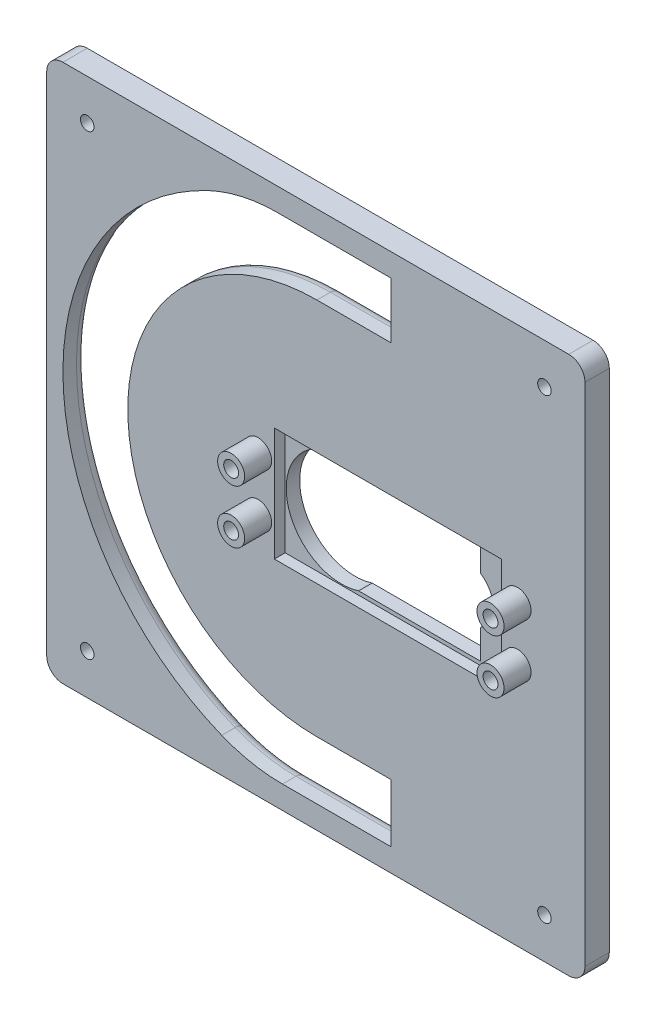
from build123d import *

# Parameters (mm, degrees)
SKETCH1_W                = 99.6
SKETCH1_H                = 99.6
SKETCH1_R                = 7.5
BOSS_EXTRUDE1_DEPTH      = 3
BOSS_EXTRUDE1_DEPTH_BACK = 1.5
CUT_EXTRUDE13_DEPTH      = 4.5
SKETCH38_R               = 2.5
SKETCH38_R_2             = 1.375
BOSS_EXTRUDE12_DEPTH     = 5
CUT_EXTRUDE35_DEPTH      = 10
CUT_EXTRUDE36_DEPTH      = 4.5
SKETCH44_R               = 1.5
CUT_EXTRUDE37_DEPTH      = 3
M3X0_5_TAPPED_HOLE1_D    = 2.5
FILLET1_R                = 3
FILLET3_R                = 2
SKETCH48_W               = 42
SKETCH48_H               = 21
CUT_EXTRUDE38_DEPTH      = 2


with BuildPart() as part:
    # Sketch1 → Boss-Extrude1 (new body, two sides)
    with BuildSketch(Plane.XY) as boss_extrude1_sk:
        with Locations((-24.95, -0.2)):
            Rectangle(SKETCH1_W, SKETCH1_H)
        with Locations((-22.104673791, 0)):
            Circle(SKETCH1_R, mode=Mode.SUBTRACT)
    extrude(amount=BOSS_EXTRUDE1_DEPTH)
    extrude(boss_extrude1_sk.sketch, amount=-BOSS_EXTRUDE1_DEPTH_BACK)

    # Sketch20 → Cut-Extrude13 (cut)
    with BuildSketch(Plane(origin=(0, 0, -1.5), x_dir=(-1, 0, 0), z_dir=(0, 0, -1))):
        with BuildLine():
            Line((11.031785139, 45.36), (32.034943377, 45.36))
            ThreePointArc((32.034943377, 45.36), (38.62370386, 44.627528684), (44.890725806, 42.465882353))
            ThreePointArc((44.890725806, 42.465882353), (71.729858041, -1.375840995), (42.371047654, -43.571764706))
            ThreePointArc((42.371047654, -43.571764706), (36.852752692, -45.207860204), (31.123570428, -45.76))
            Line((31.123570428, -45.76), (11.031785139, -45.76))
            Line((11.031785139, -45.76), (11.031785139, -35))
            Line((11.031785139, -35), (24.75, -35))
            ThreePointArc((24.75, -35), (59.75, 0), (24.75, 35))
            Line((24.75, 35), (11.031785139, 35))
            Line((11.031785139, 35), (11.031785139, 45.36))
        make_face()
    extrude(amount=-CUT_EXTRUDE13_DEPTH, mode=Mode.SUBTRACT)

    # Sketch38 → Boss-Extrude12 (add)
    with BuildSketch(Plane.XY.offset(3)):
        with Locations((-35.624093115, -4.902903378)):
            Circle(SKETCH38_R)
        with Locations((-35.624093115, -4.902903378)):
            Circle(SKETCH38_R_2, mode=Mode.SUBTRACT)
        with Locations((-35.624093115, 5)):
            Circle(SKETCH38_R)
        with Locations((-35.624093115, 5)):
            Circle(SKETCH38_R_2, mode=Mode.SUBTRACT)
        with Locations((12.375906885, 5)):
            Circle(SKETCH38_R)
        with Locations((12.375906885, 5)):
            Circle(SKETCH38_R_2, mode=Mode.SUBTRACT)
        with Locations((12.375906885, -4.902903378)):
            Circle(SKETCH38_R)
        with Locations((12.375906885, -4.902903378)):
            Circle(SKETCH38_R_2, mode=Mode.SUBTRACT)
    extrude(amount=BOSS_EXTRUDE12_DEPTH)

    # Sketch42 → Cut-Extrude35 (cut)
    with BuildSketch(Plane(origin=(0, 0, -1.5), x_dir=(-1, 0, 0), z_dir=(0, 0, -1))):
        with BuildLine():
            Line((-3.057683491, 9.75), (-3.057683491, 4.242640687))
            ThreePointArc((-3.057683491, 4.242640687), (-5.057683491, 0), (-3.057683491, -4.242640687))
            Line((-3.057683491, -4.242640687), (-3.057683491, -9.75))
            Line((-3.057683491, -9.75), (19.030038849, -9.75))
            ThreePointArc((19.030038849, -9.75), (32.442316509, 0), (19.030038849, 9.75))
            Line((19.030038849, 9.75), (-3.057683491, 9.75))
        make_face()
    extrude(amount=-CUT_EXTRUDE35_DEPTH, mode=Mode.SUBTRACT)

    # Sketch43 → Cut-Extrude36 (cut)
    with BuildSketch(Plane(origin=(0, 0, -1.5), x_dir=(-1, 0, 0), z_dir=(0, 0, -1))):
        with BuildLine():
            Line((-3.057683491, -9.75), (-3.557683491, -9.75))
            Line((-3.557683491, -9.75), (-3.557683491, -4.296321376))
            ThreePointArc((-3.557683491, -4.296321376), (-5.878167566, 0), (-3.557683491, 4.296321376))
            Line((-3.557683491, 4.296321376), (-3.557683491, 9.75))
            Line((-3.557683491, 9.75), (-3.057683491, 9.75))
            Line((-3.057683491, 9.75), (-3.057683491, 4.585346664))
            Line((-3.057683491, 4.585346664), (-3.057683491, -4.585346664))
            Line((-3.057683491, -4.585346664), (-3.057683491, -9.75))
        make_face()
    extrude(amount=-CUT_EXTRUDE36_DEPTH, mode=Mode.SUBTRACT)

    # Sketch44 → Cut-Extrude37 (cut)
    with BuildSketch(Plane.XY.offset(3)):
        with Locations((12.375906885, -4.902903378)):
            Circle(SKETCH44_R)
        with Locations((12.375906885, 5)):
            Circle(SKETCH44_R)
        with Locations((-35.624093115, 5)):
            Circle(SKETCH44_R)
        with Locations((-35.624093115, -4.902903378)):
            Circle(SKETCH44_R)
    extrude(amount=-CUT_EXTRUDE37_DEPTH, mode=Mode.SUBTRACT)

    # M3x0.5 Tapped Hole1 (through all)
    with Locations(Plane(origin=(0, 0, -1.5), x_dir=(-1, 0, 0), z_dir=(0, 0, -1))):
        with Locations((-17.35, 42.1), (-17.35, -42.5), (67.25, -42.5), (67.25, 42.1)):
            Hole(M3X0_5_TAPPED_HOLE1_D / 2)

    # Fillet1
    fillet1_edges = [part.edges().sort_by_distance(p)[0] for p in [
        (-74.75, 49.6, 0.75),
        (24.85, 49.6, 0.75),
        (24.85, -50, 0.75),
        (-74.75, -50, 0.75),
    ]]
    fillet(fillet1_edges, radius=FILLET1_R)

    # Fillet3
    fillet3_edges = [part.edges().sort_by_distance(p)[0] for p in [
        (-21.077677783, -45.76, -1.5),
        (-36.852752692, -45.207860204, -1.5),
        (-71.729858041, -1.375840995, -1.5),
        (-17.89089257, -35, -1.5),
        (-11.031785139, -40.38, -1.5),
        (-38.62370386, 44.627528684, -1.5),
        (-21.533364258, 45.36, -1.5),
        (-11.031785139, 40.18, -1.5),
        (-17.89089257, 35, -1.5),
        (-59.75, 0, -1.5),
    ]]
    fillet(fillet3_edges, radius=FILLET3_R)

    # Sketch48 → Cut-Extrude38 (cut)
    with BuildSketch(Plane.XY.offset(3)):
        with Locations((-11.624093115, 0.048548311)):
            Rectangle(SKETCH48_W, SKETCH48_H)
    extrude(amount=-CUT_EXTRUDE38_DEPTH, mode=Mode.SUBTRACT)


solid = part.part
